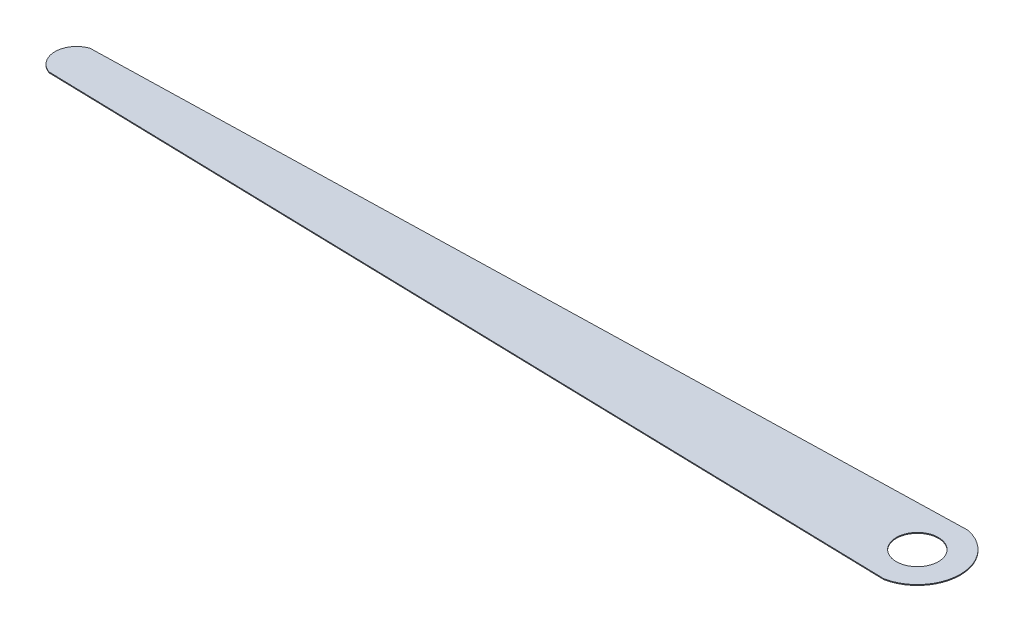
from build123d import *

# Parameters (mm, degrees)
SKETCH1_R           = 2.5
BOSS_EXTRUDE1_DEPTH = 0.1


with BuildPart() as part:
    # Sketch1 → Boss-Extrude1 (new body)
    with BuildSketch(Plane(origin=(0, 0, 0), x_dir=(1, 0, 0), z_dir=(0, 1, 0))):
        with BuildLine():
            Line((0, 0), (-101.873461229, -2.564384609))
            ThreePointArc((-101.873461229, -2.564384609), (-103.606717283, -5), (-101.873461229, -7.435615391))
            Line((-101.873461229, -7.435615391), (0, -10))
            ThreePointArc((0, -10), (4.075949785, -5), (0, 0))
        make_face()
        with Locations((-1.028794979, -5)):
            Circle(SKETCH1_R, mode=Mode.SUBTRACT)
    extrude(amount=BOSS_EXTRUDE1_DEPTH)


solid = part.part
